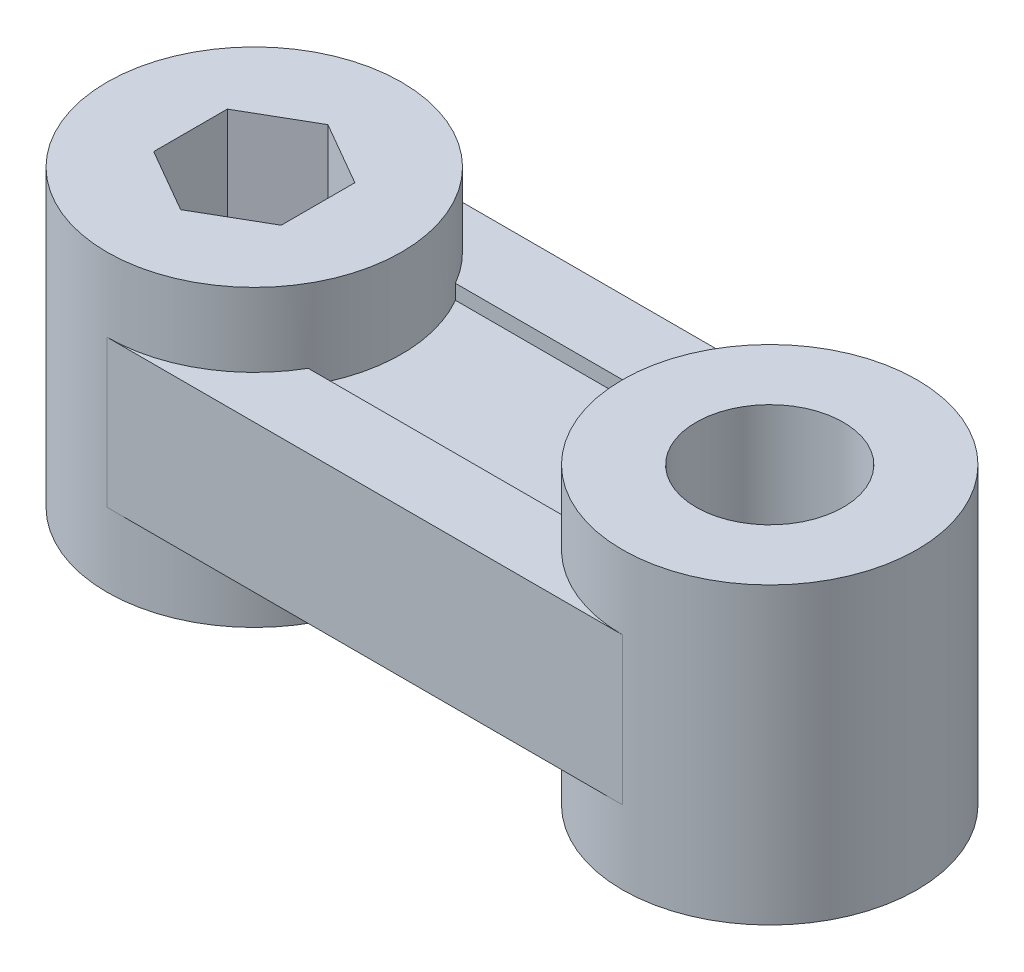
from build123d import *

# Parameters (mm, degrees)
SKETCH1_R           = 5
BOSS_EXTRUDE1_DEPTH = 20
CUT_EXTRUDE2_DEPTH  = 5
CUT_EXTRUDE3_DEPTH  = 1
CUT_EXTRUDE4_DEPTH  = 5
CUT_EXTRUDE5_DEPTH  = 1


with BuildPart() as part:
    # Sketch1 → Boss-Extrude1 (new body)
    with BuildSketch(Plane(origin=(0, 0, 0), x_dir=(1, 0, 0), z_dir=(0, 1, 0))):
        with BuildLine():
            Line((0, 10), (35, 10))
            ThreePointArc((35, 10), (45, 0), (35, -10))
            Line((35, -10), (0, -10))
            ThreePointArc((0, -10), (-10, 0), (0, 10))
        make_face()
        with Locations((35, 0)):
            Circle(SKETCH1_R, mode=Mode.SUBTRACT)
        Polygon((0, 5), (-4.330127, 2.5), (-4.330127, -2.5), (0, -5), (4.330127, -2.5), (4.330127, 2.5), align=None, mode=Mode.SUBTRACT)
    extrude(amount=BOSS_EXTRUDE1_DEPTH)

    # Sketch2 → Cut-Extrude2 (cut)
    with BuildSketch(Plane(origin=(0, 20, 0), x_dir=(1, 0, 0), z_dir=(0, 1, 0))):
        with BuildLine():
            Line((0, 10), (35, 10))
            ThreePointArc((35, 10), (25, 0), (35, -10))
            Line((35, -10), (0, -10))
            ThreePointArc((0, -10), (10, 0), (0, 10))
        make_face()
    extrude(amount=-CUT_EXTRUDE2_DEPTH, mode=Mode.SUBTRACT)

    # Sketch3 → Cut-Extrude3 (cut)
    with BuildSketch(Plane(origin=(0, 15, 0), x_dir=(1, 0, 0), z_dir=(0, 1, 0))):
        with BuildLine():
            Line((26.339746, 5), (8.660254, 5))
            ThreePointArc((8.660254, 5), (10, 0), (8.660254, -5))
            Line((8.660254, -5), (26.339746, -5))
            ThreePointArc((26.339746, -5), (25, 0), (26.339746, 5))
        make_face()
    extrude(amount=-CUT_EXTRUDE3_DEPTH, mode=Mode.SUBTRACT)

    # Sketch4 → Cut-Extrude4 (cut)
    with BuildSketch(Plane.XZ):
        with BuildLine():
            ThreePointArc((0, -10), (5, -8.660254), (8.660254, -5))
            ThreePointArc((8.660254, -5), (10, 0), (8.660254, 5))
            ThreePointArc((8.660254, 5), (5, 8.660254), (0, 10))
            Line((0, 10), (35, 10))
            ThreePointArc((35, 10), (30, 8.660254), (26.339746, 5))
            ThreePointArc((26.339746, 5), (25, 0), (26.339746, -5))
            ThreePointArc((26.339746, -5), (30, -8.660254), (35, -10))
            Line((35, -10), (0, -10))
        make_face()
    extrude(amount=-CUT_EXTRUDE4_DEPTH, mode=Mode.SUBTRACT)

    # Sketch5 → Cut-Extrude5 (cut)
    with BuildSketch(Plane.XZ.offset(-5)):
        with BuildLine():
            ThreePointArc((8.660254, 5), (10, 0), (8.660254, -5))
            Line((8.660254, -5), (26.339746, -5))
            ThreePointArc((26.339746, -5), (25, 0), (26.339746, 5))
            Line((26.339746, 5), (8.660254, 5))
        make_face()
    extrude(amount=-CUT_EXTRUDE5_DEPTH, mode=Mode.SUBTRACT)


solid = part.part
